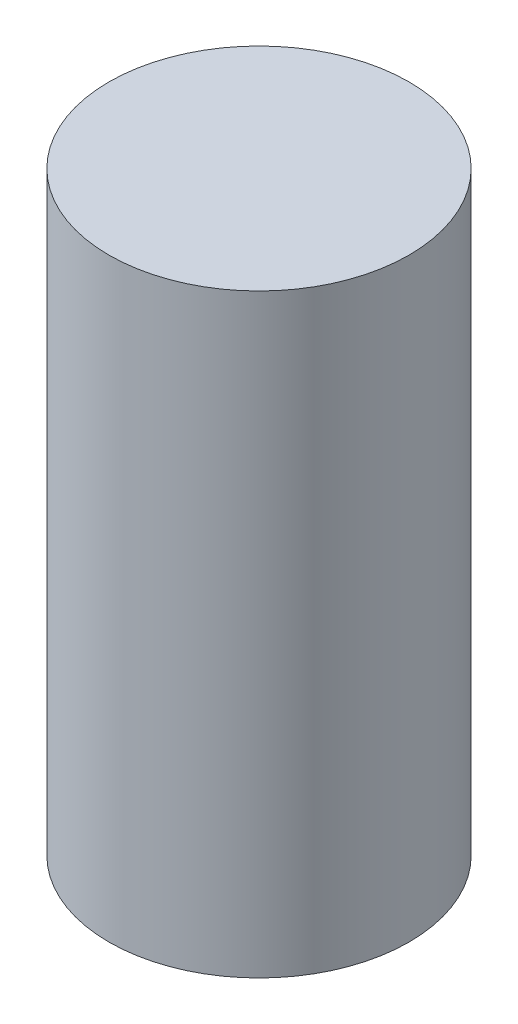
from build123d import *

# Parameters (mm, degrees)
SKETCH_1_R      = 2.9
EXTRUDE_1_DEPTH = 11.5


with BuildPart() as part:
    # Эскиз1 → Бобышка-Вытянуть1 (new body)
    with BuildSketch(Plane(origin=(0, 0, 0), x_dir=(1, 0, 0), z_dir=(0, 1, 0))):
        Circle(SKETCH_1_R)
    extrude(amount=EXTRUDE_1_DEPTH)


solid = part.part
